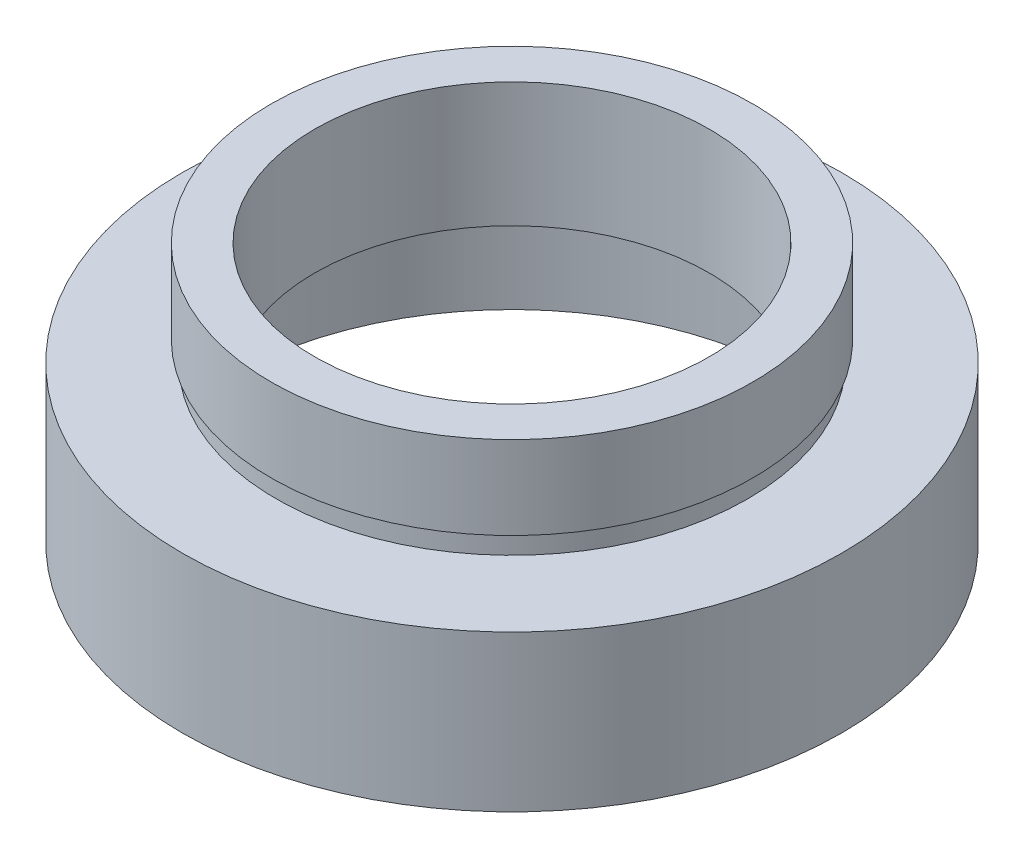
from build123d import *


with BuildPart() as part:
    # 草图1 → 旋转1 (revolve)
    with BuildSketch(Plane.XY, mode=Mode.PRIVATE) as revolve_1_sk:
        Polygon((13.75, 0), (13.75, 5.5), (14.35, 5.5), (14.35, 6.5), (9.5, 6.5), (9.5, 12.5), (11.6, 12.5), (11.6, 8.5), (11.35, 8.5), (11.35, 7.5), (15.875, 7.5), (15.875, 0), align=None)
    revolve(revolve_1_sk.sketch.rotate(Axis((0, 16.886018237, 0), (0, -1, 0)), 180), axis=Axis((0, 16.886018237, 0), (0, -1, 0)))  # turned: the seam where the file's is


solid = part.part
